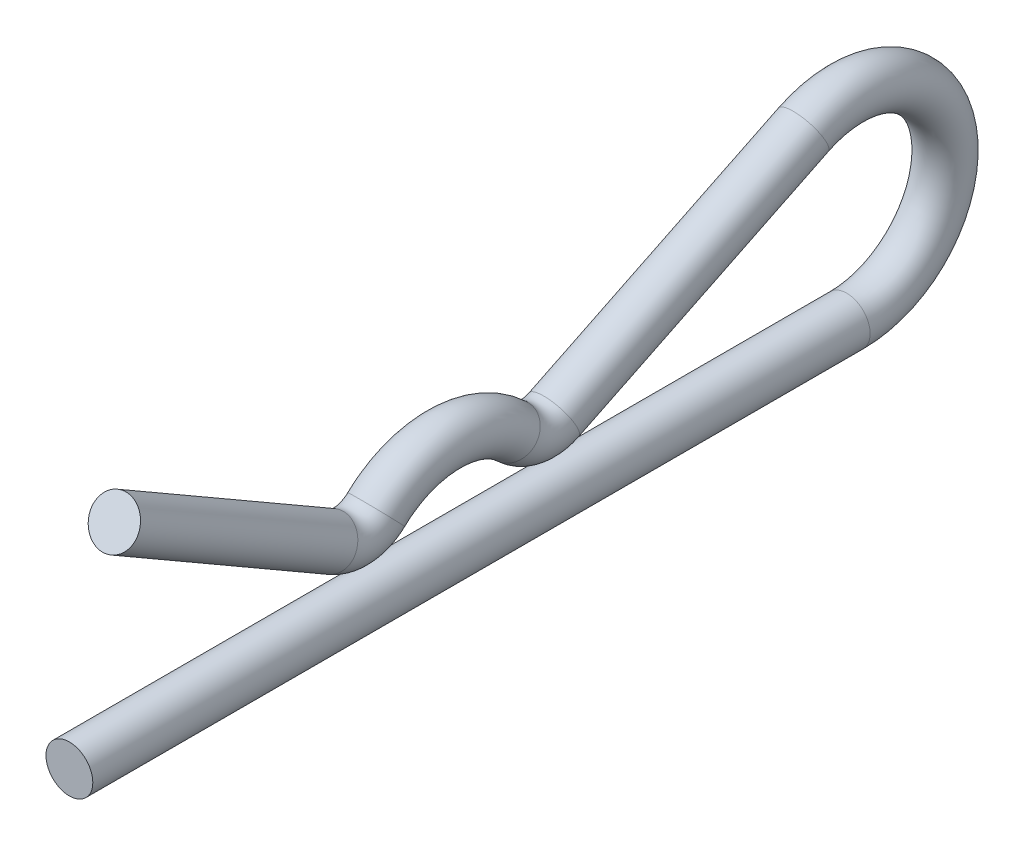
from build123d import *

# Parameters (mm, degrees)
SKETCH1_R = 0.9921875


with BuildPart() as part:
    # Sweep1: sweep along a path in Sketch2
    with BuildLine(Plane(origin=(0, 0, 0), x_dir=(0, 0, -1), z_dir=(1, 0, 0))) as sweep1_path:
        Line((0, 0), (32.940625, 0))
        ThreePointArc((32.940625, 0), (37.000473579, 5.10691149), (31.109588068, 7.910549013))
        Line((31.109588068, 7.910549013), (20.541287879, 2.741145019))
        ThreePointArc((20.541287879, 2.741145019), (19.6017393, 2.598242928), (18.748922414, 3.017618534))
        ThreePointArc((18.748922414, 3.017618534), (15.875, 4.1671875), (13.001077586, 3.017618534))
        ThreePointArc((13.001077586, 3.017618534), (12.094255078, 2.59085938), (11.1125, 2.792372171))
        Line((11.1125, 2.792372171), (1.905, 8.108324775))
    # Sketch1 → Sweep1 (sweep)
    with BuildSketch(Plane.XY):
        Circle(SKETCH1_R)
    sweep(path=sweep1_path.line)


solid = part.part
